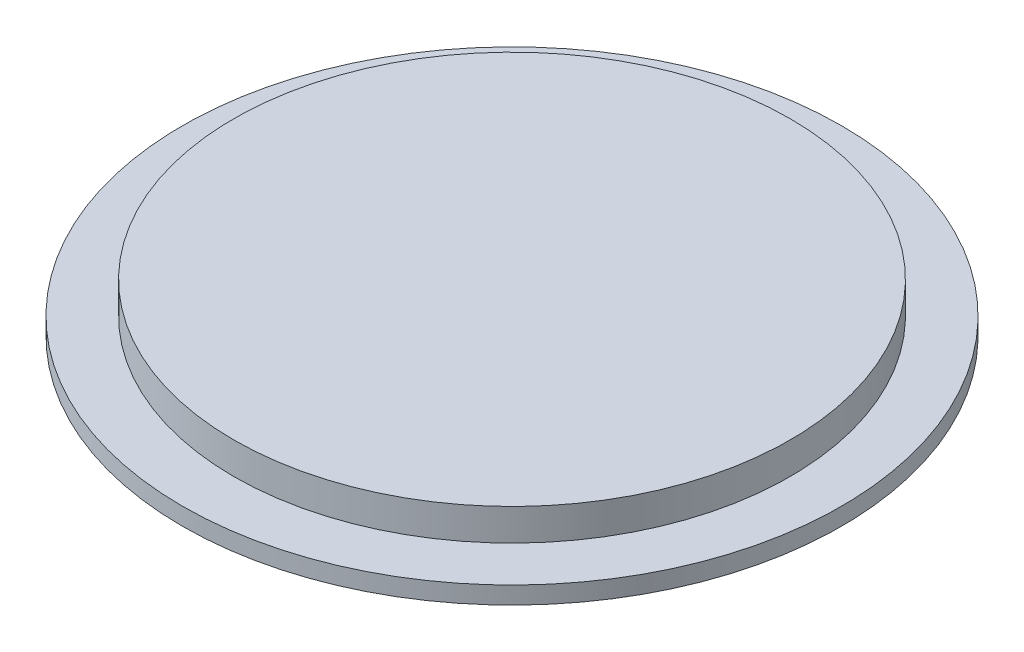
from build123d import *

# Parameters (mm, degrees)
SKETCH1_R           = 16.256
BOSS_EXTRUDE1_DEPTH = 2.8702
SKETCH2_R           = 19.256
BOSS_EXTRUDE2_DEPTH = 1.016


with BuildPart() as part:
    # Sketch1 → Boss-Extrude1 (new body)
    with BuildSketch(Plane(origin=(0, 0, 0), x_dir=(1, 0, 0), z_dir=(0, 1, 0))):
        Circle(SKETCH1_R)
    extrude(amount=BOSS_EXTRUDE1_DEPTH)

    # Sketch2 → Boss-Extrude2 (add)
    with BuildSketch(Plane.XZ):
        Circle(SKETCH2_R)
    extrude(amount=-BOSS_EXTRUDE2_DEPTH)


solid = part.part
